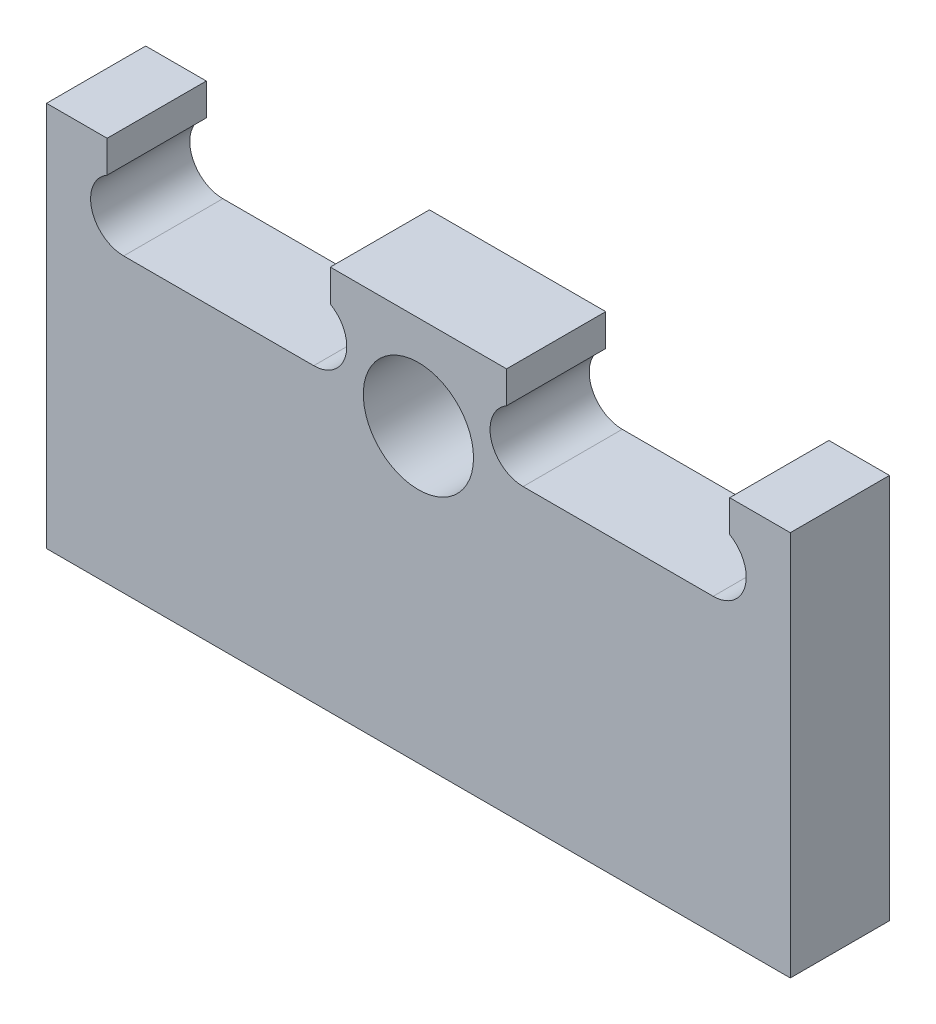
from build123d import *

# Parameters (mm, degrees)
CROQUIS1_R              = 10
SALIENTE_EXTRUIR1_DEPTH = 18


with BuildPart() as part:
    # Croquis1 → Saliente-Extruir1 (new body)
    with BuildSketch(Plane.XY):
        with BuildLine():
            Line((0, 0), (0, 70))
            Line((0, 70), (11, 70))
            Line((11, 70), (11, 64.196152423))
            ThreePointArc((11, 64.196152423), (8.204445042, 57.447085729), (14, 53))
            Line((14, 53), (48.5, 53))
            ThreePointArc((48.5, 53), (54.295554958, 57.447085729), (51.5, 64.196152423))
            Line((51.5, 64.196152423), (51.5, 70))
            Line((51.5, 70), (83.5, 70))
            Line((83.5, 70), (83.5, 64.196152423))
            ThreePointArc((83.5, 64.196152423), (80.704445042, 57.447085729), (86.5, 53))
            Line((86.5, 53), (121, 53))
            ThreePointArc((121, 53), (126.795554958, 57.447085729), (124, 64.196152423))
            Line((124, 64.196152423), (124, 70))
            Line((124, 70), (135, 70))
            Line((135, 70), (135, 0))
            Line((135, 0), (0, 0))
        make_face()
        with Locations((67.5, 53)):
            Circle(CROQUIS1_R, mode=Mode.SUBTRACT)
    extrude(amount=SALIENTE_EXTRUIR1_DEPTH)


solid = part.part
